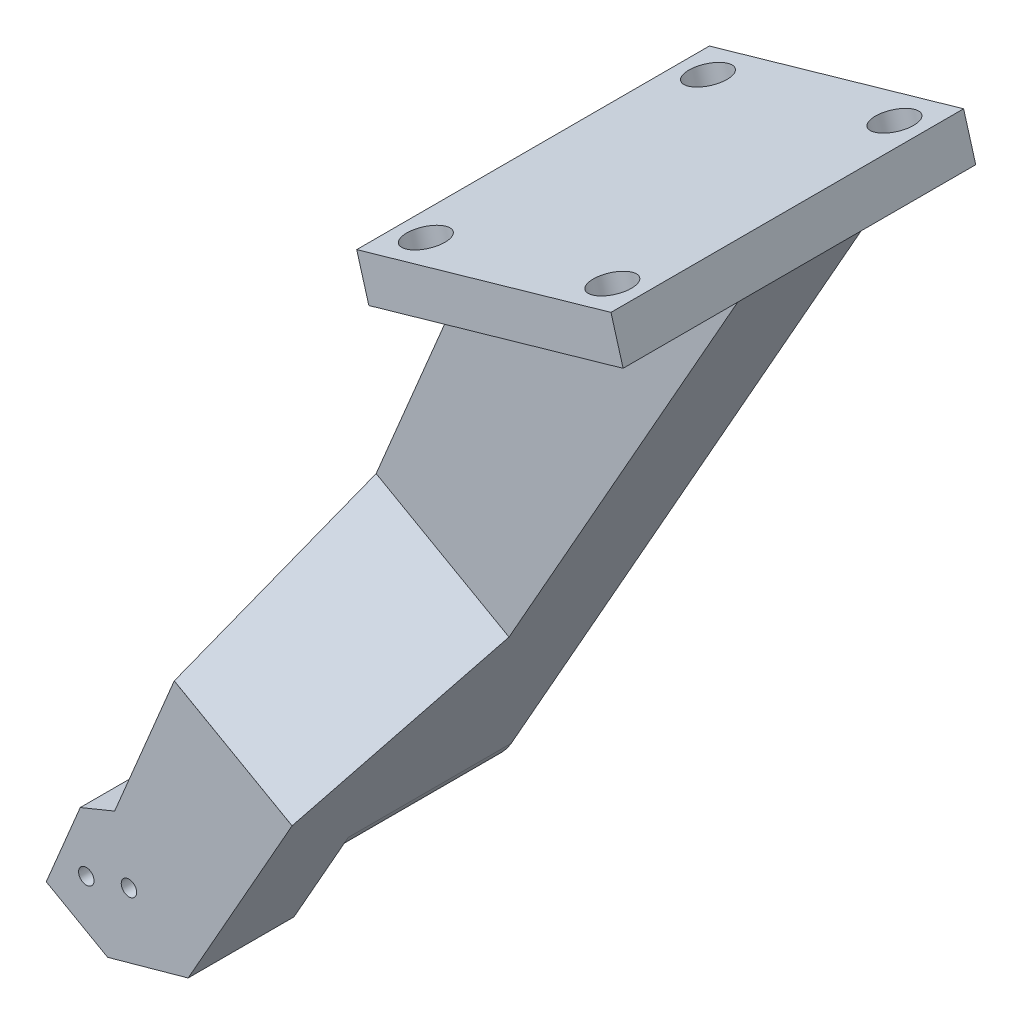
from build123d import *

# Parameters (mm, degrees)
SKETCH3_W                = 30
SKETCH3_H                = 39.99999999999999
SKETCH3_R                = 2.2500000000000107
BOSS_EXTRUDE1_DEPTH      = 5
BOSS_EXTRUDE2_DEPTH      = 7
BOSS_EXTRUDE2_DEPTH_BACK = 7
BOSS_EXTRUDE3_DEPTH      = 4.493237048
BOSS_EXTRUDE4_DEPTH      = 2
BOSS_EXTRUDE5_DEPTH      = 10
SKETCH8_R                = 0.874999999999402
SKETCH8_R_2              = 0.8749999999993996
CUT_EXTRUDE1_DEPTH       = 128.20148900625736
CHAMFER1_SIZE            = 16.49


with BuildPart() as part:
    # Sketch3 → Boss-Extrude1 (new body)
    with BuildSketch(Plane(origin=(-20.656096268089573, 72.16840410421906, 1.396e-13), x_dir=(0.9613952185534441, 0.2751712807372447, 0), z_dir=(0.2751712807372447, -0.9613952185534441, -1.905836610257915e-15))):
        with Locations((81.70857094012555, -8.293237047851846)):
            Rectangle(SKETCH3_W, SKETCH3_H)
        with Locations((92.70857094012555, 7.706762952148144)):
            Circle(SKETCH3_R, mode=Mode.SUBTRACT)
        with Locations((70.70857094012555, 7.706762952148144)):
            Circle(SKETCH3_R, mode=Mode.SUBTRACT)
        with Locations((92.70857094012555, -24.293237047851843)):
            Circle(SKETCH3_R, mode=Mode.SUBTRACT)
        with Locations((70.70857094012555, -24.293237047851843)):
            Circle(SKETCH3_R, mode=Mode.SUBTRACT)
    extrude(amount=BOSS_EXTRUDE1_DEPTH)

    # Sketch4 → Boss-Extrude2 (add, two sides: drawn at the far end of the back side and taken through both)
    with BuildSketch(Plane.XY.offset(-8.293237047851855).offset(-BOSS_EXTRUDE2_DEPTH_BACK)):
        with BuildLine():
            Line((73.69491783056992, 93.97284933531479), (44.8530612739666, 85.71771091319745))
            Line((44.8530612739666, 85.71771091319745), (21.868275221764016, 30.766725890030358))
            ThreePointArc((21.868275221764016, 30.766725890030358), (24.444464826602115, 21.20831351558636), (34.00287720104611, 23.78450312042446))
            Line((34.00287720104611, 23.78450312042446), (73.69491783056992, 93.97284933531479))
        make_face()
    extrude(amount=BOSS_EXTRUDE2_DEPTH + BOSS_EXTRUDE2_DEPTH_BACK)

    # Sketch5 → Boss-Extrude3 (add)
    with BuildSketch(Plane.XY.offset(-1.2932370478518544)):
        with BuildLine():
            Line((34.00287720104611, 23.78450312042448), (39.63747674144046, 33.74829477867678))
            Line((39.63747674144046, 33.74829477867678), (26.275931115955906, 41.30434988526449))
            Line((26.275931115955906, 41.30434988526449), (21.868275221764016, 30.766725890030376))
            ThreePointArc((21.868275221764016, 30.766725890030376), (24.444464826602115, 21.20831351558638), (34.00287720104611, 23.78450312042448))
        make_face()
    extrude(amount=BOSS_EXTRUDE3_DEPTH)

    # Sketch6 → Boss-Extrude4 (add)
    with BuildSketch(Plane.XY.offset(3.199999999999975)):
        with BuildLine():
            Line((14.367137951998398, 12.833346791724153), (22.10488555177782, 16.08852481695844))
            ThreePointArc((22.10488555177782, 16.08852481695844), (23.553783162359977, 19.026709419920138), (20.85003386751253, 20.876566927309664))
            Line((20.85003386751253, 20.876566927309664), (17.573963093227494, 20.50007903397223))
            Line((17.573963093227494, 20.50007903397223), (26.275931115955906, 41.30434988526449))
            Line((26.275931115955906, 41.30434988526449), (39.63747674144046, 33.74829477867678))
            Line((39.63747674144046, 33.74829477867678), (27.851332502459574, 12.906585477167601))
            Line((27.851332502459574, 12.906585477167601), (18.71941105293458, 10.372103436249658))
            Line((18.71941105293458, 10.372103436249658), (14.367137951998398, 12.833346791724153))
        make_face()
    extrude(amount=BOSS_EXTRUDE4_DEPTH)

    # Sketch9 → Boss-Extrude5 (add)
    with BuildSketch(Plane.XY.offset(5.199999999999974)):
        Polygon((19.512348726132714, 25.134283574349986), (26.275931115955906, 41.30434988526451), (39.637476741440466, 33.74829477867679), (27.851332502459464, 12.906585477167425), (18.719411052934504, 10.37210343624943), (14.367137951998316, 12.833346791723917), (11.755774091436686, 14.310092805008848), (15.614590337202541, 23.53557583742582), align=None)
    extrude(amount=BOSS_EXTRUDE5_DEPTH)

    # Sketch8 → Cut-Extrude1 (cut, through all)
    with BuildSketch(Plane.XY.offset(3.199999999999975)):
        with Locations((21.135456701762944, 18.39291360897205)):
            Circle(SKETCH8_R)
        with Locations((16.298803780568512, 17.12532198707588)):
            Circle(SKETCH8_R_2)
    extrude(amount=CUT_EXTRUDE1_DEPTH, mode=Mode.SUBTRACT)

    # Chamfer1
    chamfer1_edges = [part.edges().sort_by_distance(p)[0] for p in [
        (32.95670392869818, 37.52632233197063, -1.2932370478518544),
    ]]
    chamfer(chamfer1_edges, length=CHAMFER1_SIZE)


solid = part.part
